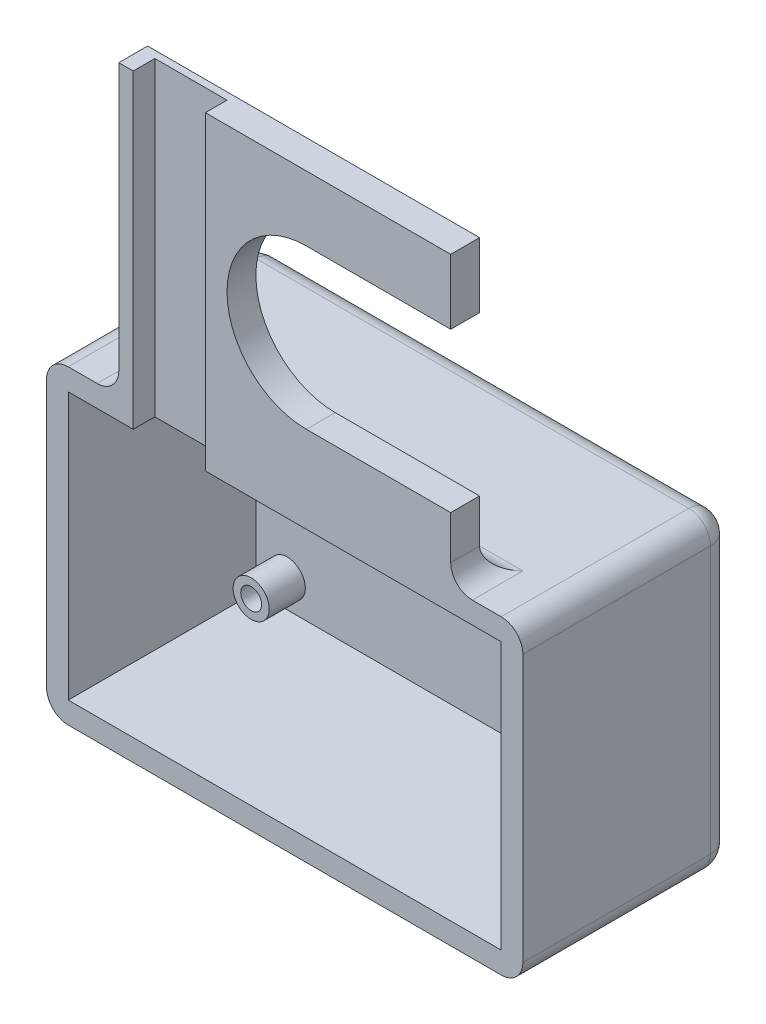
from build123d import *

# Parameters (mm, degrees)
SKETCH_1_W          = 66
SKETCH_1_H          = 43
SKETCH_1_W_2        = 60
SKETCH_1_H_2        = 37
EXTRUDE_1_DEPTH     = 26
SKETCH_2_W          = 66
SKETCH_2_H          = 43
EXTRUDE_2_DEPTH     = 3
EXTRUDE_3_DEPTH     = 40
CUT_EXTRUDE_1_REACH = 45
SKETCH_4_W          = 10
SKETCH_4_H          = 3
SKETCH_6_R          = 2.5
SKETCH_6_R_2        = 1.45
EXTRUDE_5_DEPTH     = 5
CUT_EXTRUDE_2_REACH = 31
FILLET_1_R          = 3
FILLET_2_R          = 3


with BuildPart() as part:
    # 草图1 → 凸台-拉伸1 (new body)
    with BuildSketch(Plane.XY):
        with Locations((-0.837138389, -4.179180765)):
            Rectangle(SKETCH_1_W, SKETCH_1_H)
        with Locations((-0.837138389, -4.179180765)):
            Rectangle(SKETCH_1_W_2, SKETCH_1_H_2, mode=Mode.SUBTRACT)
    extrude(amount=EXTRUDE_1_DEPTH)

    # 草图2 → 凸台-拉伸2 (add)
    with BuildSketch(Plane(origin=(0, 0, 0), x_dir=(-1, 0, 0), z_dir=(0, 0, -1))):
        with Locations((0.837138389, -4.179180765)):
            Rectangle(SKETCH_2_W, SKETCH_2_H)
    extrude(amount=EXTRUDE_2_DEPTH)

    # 草图3 → 凸台-拉伸3 (add)
    with BuildSketch(Plane(origin=(0, 17.320819235, 0), x_dir=(1, 0, 0), z_dir=(0, 1, 0))):
        Polygon((-21.837138389, -26), (-21.837138389, -23), (-11.837138389, -23), (-11.837138389, -26), (22.162861611, -26), (22.162861611, -22), (-23.837138389, -22), (-23.837138389, -26), align=None)
    extrude(amount=EXTRUDE_3_DEPTH)

    # 草图4 → 切除-拉伸1 (cut, up to next)
    with BuildSketch(Plane(origin=(0, 17.320819235, 0), x_dir=(1, 0, 0), z_dir=(0, 1, 0)), mode=Mode.PRIVATE) as cut_extrude_1_sk1:
        with Locations((-16.837138389, -24.5)):
            Rectangle(SKETCH_4_W, SKETCH_4_H)
    cut_extrude_1_tool1 = extrude(cut_extrude_1_sk1.sketch, amount=-CUT_EXTRUDE_1_REACH, mode=Mode.PRIVATE) & part.part
    add(cut_extrude_1_tool1.solids().sort_by_distance((-16.837138, 17.320819, 24.5))[0], mode=Mode.SUBTRACT)

    # 草图6 → 凸台-拉伸5 (add)
    with BuildSketch(Plane.XY):
        with Locations((24.812861611, -18.829180765)):
            Circle(SKETCH_6_R)
        with Locations((24.812861611, -18.829180765)):
            Circle(SKETCH_6_R_2, mode=Mode.SUBTRACT)
        with Locations((-26.487138389, -18.829180765)):
            Circle(SKETCH_6_R)
        with Locations((-26.487138389, -18.829180765)):
            Circle(SKETCH_6_R_2, mode=Mode.SUBTRACT)
        with Locations((24.812861611, 10.470819235)):
            Circle(SKETCH_6_R)
        with Locations((24.812861611, 10.470819235)):
            Circle(SKETCH_6_R_2, mode=Mode.SUBTRACT)
        with Locations((-26.487138389, 10.470819235)):
            Circle(SKETCH_6_R)
        with Locations((-26.487138389, 10.470819235)):
            Circle(SKETCH_6_R_2, mode=Mode.SUBTRACT)
    extrude(amount=EXTRUDE_5_DEPTH)

    # 草图10 → 切除-拉伸2 (cut, up to next)
    with BuildSketch(Plane.XY.offset(26), mode=Mode.PRIVATE) as cut_extrude_2_sk1:
        with BuildLine():
            Line((2.162861611, 26.320819235), (22.162861611, 26.320819235))
            Line((22.162861611, 26.320819235), (22.162861611, 48.320819235))
            Line((22.162861611, 48.320819235), (2.162861611, 48.320819235))
            ThreePointArc((2.162861611, 48.320819235), (-8.837138389, 37.320819235), (2.162861611, 26.320819235))
        make_face()
    cut_extrude_2_tool1 = extrude(cut_extrude_2_sk1.sketch, amount=-CUT_EXTRUDE_2_REACH, mode=Mode.PRIVATE) & part.part
    add(cut_extrude_2_tool1.solids().sort_by_distance((7.737936, 37.320819, 26))[0], mode=Mode.SUBTRACT)

    # 圆角1
    fillet_1_edges = [part.edges().sort_by_distance(p)[0] for p in [
        (32.162861611, -4.179180765, -3),
        (-0.837138389, -25.679180765, -3),
        (-33.837138389, -4.179180765, -3),
        (-0.837138389, 17.320819235, -3),
        (32.162861611, -25.679180765, 11.5),
        (-33.837138389, -25.679180765, 11.5),
        (-33.837138389, 17.320819235, 11.5),
        (32.162861611, 17.320819235, 11.5),
    ]]
    fillet(fillet_1_edges, radius=FILLET_1_R)

    # 圆角2
    fillet_2_edges = [part.edges().sort_by_distance(p)[0] for p in [
        (-23.837138389, 17.320819235, 24),
        (22.162861611, 17.320819235, 24),
        (-0.837138389, 17.320819235, 22),
    ]]
    fillet(fillet_2_edges, radius=FILLET_2_R)


solid = part.part
